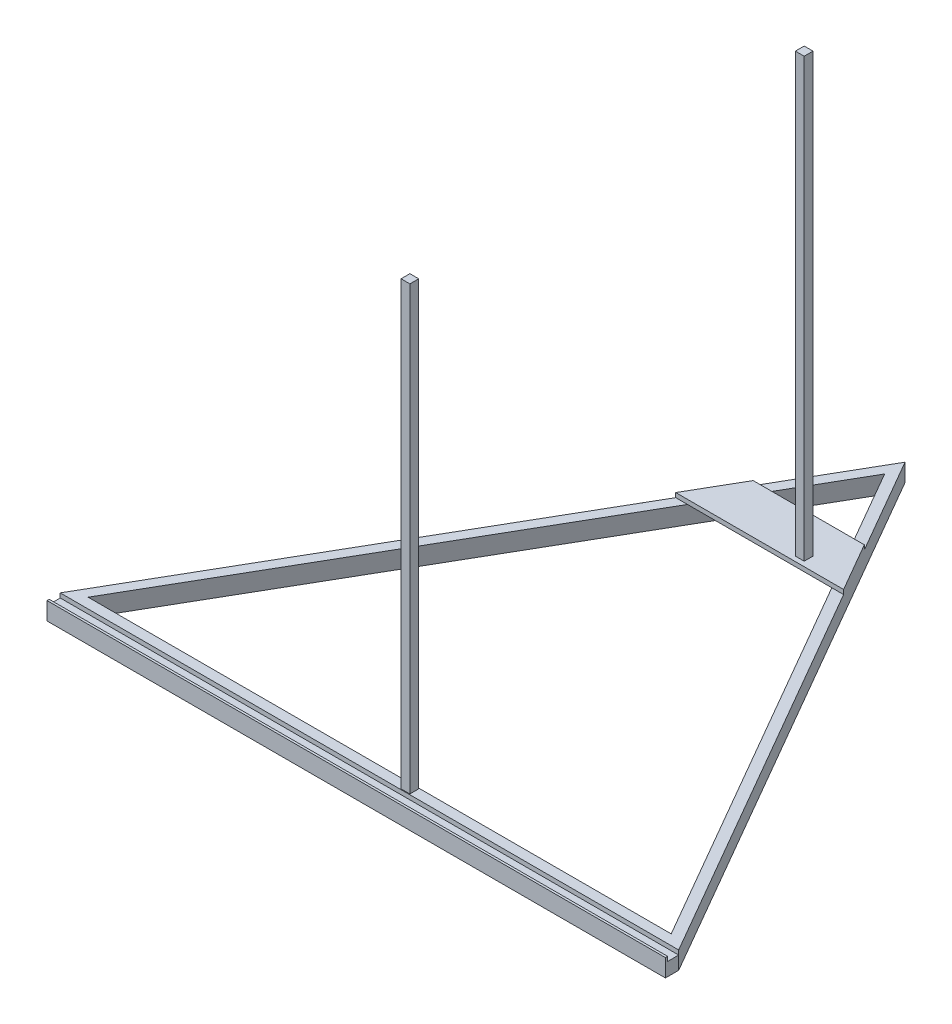
from build123d import *

# Parameters (mm, degrees)
BOSS_EXTRUDE1_DEPTH = 20
SKETCH2_W           = 700
SKETCH2_H           = 15
BOSS_EXTRUDE2_DEPTH = 20
SKETCH6_W           = 10
SKETCH6_H           = 10
BOSS_EXTRUDE3_DEPTH = 500
BOSS_EXTRUDE4_DEPTH = 5
SKETCH8_W           = 10
SKETCH8_H           = 10
BOSS_EXTRUDE5_DEPTH = 495
SKETCH4_W           = 700
SKETCH4_H           = 12.5
CUT_EXTRUDE2_DEPTH  = 5


with BuildPart() as part:
    # Sketch1 → Boss-Extrude1 (new body)
    with BuildSketch(Plane(origin=(0, 0, 0), x_dir=(1, 0, 0), z_dir=(0, 1, 0))):
        Polygon((0, 404.145188433), (-350, -202.072594216), (350, -202.072594216), align=None)
        Polygon((0, 381.051177665), (-330, -190.525588833), (330, -190.525588833), align=None, mode=Mode.SUBTRACT)
    extrude(amount=BOSS_EXTRUDE1_DEPTH)

    # Sketch2 → Boss-Extrude2 (add)
    with BuildSketch(Plane(origin=(0, 0, 0), x_dir=(1, 0, 0), z_dir=(0, 1, 0))):
        with Locations((0, -209.572594216)):
            Rectangle(SKETCH2_W, SKETCH2_H)
    extrude(amount=BOSS_EXTRUDE2_DEPTH)

    # Sketch6 → Boss-Extrude3 (add)
    with BuildSketch(Plane(origin=(0, 20, 0), x_dir=(1, 0, 0), z_dir=(0, 1, 0))):
        with Locations((40, -196.3)):
            Rectangle(SKETCH6_W, SKETCH6_H)
    extrude(amount=BOSS_EXTRUDE3_DEPTH)

    # Sketch7 → Boss-Extrude4 (add)
    with BuildSketch(Plane(origin=(0, 20, 0), x_dir=(1, 0, 0), z_dir=(0, 1, 0))):
        Polygon((62.94207364, 295.126318955), (-62.94207364, 295.126318955), (-95, 239.600361714), (95, 239.600361714), align=None)
    extrude(amount=BOSS_EXTRUDE4_DEPTH)

    # Sketch8 → Boss-Extrude5 (add)
    with BuildSketch(Plane(origin=(0, 25, 0), x_dir=(1, 0, 0), z_dir=(0, 1, 0))):
        with Locations((40, 250)):
            Rectangle(SKETCH8_W, SKETCH8_H)
    extrude(amount=BOSS_EXTRUDE5_DEPTH)

    # Sketch4 → Cut-Extrude2 (cut)
    with BuildSketch(Plane(origin=(0, 20, 0), x_dir=(1, 0, 0), z_dir=(0, 1, 0))):
        with Locations((0, -208.322594216)):
            Rectangle(SKETCH4_W, SKETCH4_H)
    extrude(amount=-CUT_EXTRUDE2_DEPTH, mode=Mode.SUBTRACT)


solid = part.part
